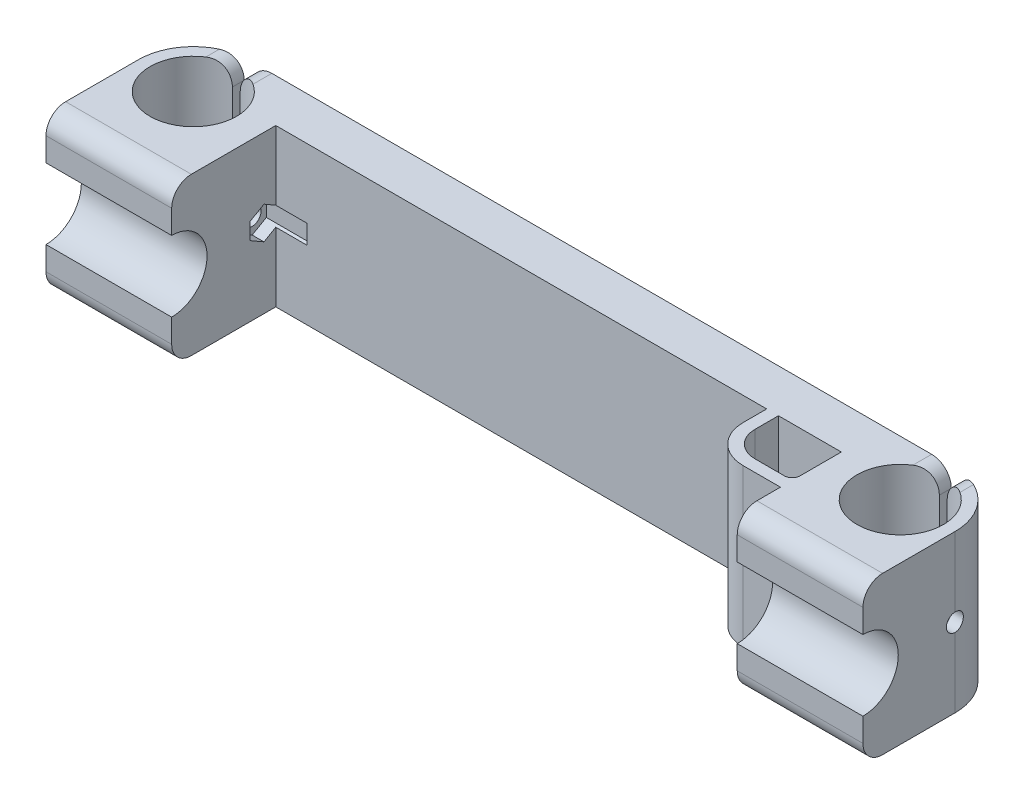
from build123d import *

# Parameters (mm, degrees)
SKETCH1_R               = 11
BOSS_EXTRUDE1_DEPTH     = 40
BOSS_EXTRUDE2_DEPTH     = 32
SKETCH4_W               = 144
SKETCH4_H               = 40
BOSS_EXTRUDE4_DEPTH     = 5
BOSS_EXTRUDE5_DEPTH     = 32
CUT_EXTRUDE2_DEPTH      = 3
SKETCH6_W               = 120
SKETCH6_H               = 20
CUT_EXTRUDE3_DEPTH      = 5
SKETCH8_W               = 2
SKETCH8_H               = 40
CUT_EXTRUDE_THIN1_DEPTH = 18
FILLET2_R               = 5
SKETCH9_R               = 2.25
CUT_EXTRUDE4_DEPTH      = 226
CUT_EXTRUDE5_START      = -3
CUT_EXTRUDE5_DEPTH      = 11
BOSS_EXTRUDE6_DEPTH     = 40
FILLET3_R               = 2


with BuildPart() as part:
    # Sketch1 → Boss-Extrude1 (new body)
    with BuildSketch(Plane(origin=(0, 0, 0), x_dir=(1, 0, 0), z_dir=(0, 1, 0))):
        with BuildLine():
            Line((137.460581558, -14.5), (119.460581558, -14.5))
            Line((119.460581558, -14.5), (119.460581558, 7.5))
            Line((119.460581558, 7.5), (-24.539418442, 7.5))
            Line((-24.539418442, 7.5), (-24.539418442, -14.5))
            Line((-24.539418442, -14.5), (-42.539418442, -14.5))
            Line((-42.539418442, -14.5), (-56.539418442, -14.5))
            Line((-56.539418442, -14.5), (-56.539418442, -0.5))
            ThreePointArc((-56.539418442, -0.5), (-52.438913379, 9.399494937), (-42.539418442, 13.5))
            Line((-42.539418442, 13.5), (137.460581558, 13.5))
            ThreePointArc((137.460581558, 13.5), (147.360076494, 9.399494937), (151.460581558, -0.5))
            Line((151.460581558, -0.5), (151.460581558, -14.5))
            Line((151.460581558, -14.5), (137.460581558, -14.5))
        make_face()
        with Locations((-42.539418442, -0.5)):
            Circle(SKETCH1_R, mode=Mode.SUBTRACT)
        with Locations((137.460581558, -0.5)):
            Circle(SKETCH1_R, mode=Mode.SUBTRACT)
    extrude(amount=BOSS_EXTRUDE1_DEPTH)

    # Sketch2 → Boss-Extrude2 (add)
    with BuildSketch(Plane.ZY.offset(56.539418442)):
        with BuildLine():
            Line((14.5, 40), (19, 40))
            ThreePointArc((19, 40), (22.535533906, 38.535533906), (24, 35))
            Line((24, 35), (24, 29))
            ThreePointArc((24, 29), (15, 20), (24, 11))
            Line((24, 11), (24, 5))
            ThreePointArc((24, 5), (22.535533906, 1.464466094), (19, 0))
            Line((19, 0), (14.5, 0))
            Line((14.5, 0), (14.5, 40))
        make_face()
    extrude(amount=-BOSS_EXTRUDE2_DEPTH)

    # Sketch4 → Boss-Extrude4 (add)
    with BuildSketch(Plane.XY.offset(-7.5)):
        with Locations((47.460581558, 20)):
            Rectangle(SKETCH4_W, SKETCH4_H)
    extrude(amount=BOSS_EXTRUDE4_DEPTH)

    # Sketch3 → Boss-Extrude5 (add)
    with BuildSketch(Plane(origin=(151.460581558, 0, 0), x_dir=(0, 0, -1), z_dir=(1, 0, 0))):
        with BuildLine():
            Line((-24, 11), (-24, 5))
            ThreePointArc((-24, 5), (-22.535533906, 1.464466094), (-19, 0))
            Line((-19, 0), (-14.5, 0))
            Line((-14.5, 0), (-14.5, 40))
            Line((-14.5, 40), (-19, 40))
            ThreePointArc((-19, 40), (-22.535533906, 38.535533906), (-24, 35))
            Line((-24, 35), (-24, 29))
            ThreePointArc((-24, 29), (-15, 20), (-24, 11))
        make_face()
    extrude(amount=-BOSS_EXTRUDE5_DEPTH)

    # Sketch5 → Cut-Extrude2 (cut)
    with BuildSketch(Plane(origin=(0, 0, -13.5), x_dir=(-1, 0, 0), z_dir=(0, 0, -1))):
        with BuildLine():
            Line((32.539418442, 35), (-127.460581558, 35))
            ThreePointArc((-127.460581558, 35), (-130.996115464, 33.535533906), (-132.460581558, 30))
            Line((-132.460581558, 30), (-132.460581558, 10))
            ThreePointArc((-132.460581558, 10), (-130.996115464, 6.464466094), (-127.460581558, 5))
            Line((-127.460581558, 5), (32.539418442, 5))
            ThreePointArc((32.539418442, 5), (36.074952348, 6.464466094), (37.539418442, 10))
            Line((37.539418442, 10), (37.539418442, 30))
            ThreePointArc((37.539418442, 30), (36.074952348, 33.535533906), (32.539418442, 35))
        make_face()
    extrude(amount=-CUT_EXTRUDE2_DEPTH, mode=Mode.SUBTRACT)

    # Sketch6 → Cut-Extrude3 (cut)
    with BuildSketch(Plane(origin=(0, 0, -10.5), x_dir=(-1, 0, 0), z_dir=(0, 0, -1))):
        with Locations((-47.460581558, 20)):
            Rectangle(SKETCH6_W, SKETCH6_H)
    extrude(amount=-CUT_EXTRUDE3_DEPTH, mode=Mode.SUBTRACT)

    # Sketch8 → Cut-Extrude-Thin1 (cut)
    with BuildSketch(Plane(origin=(0, 0, -13.5), x_dir=(-1, 0, 0), z_dir=(0, 0, -1))):
        with Locations((-137.460581558, 20)):
            Rectangle(SKETCH8_W, SKETCH8_H)
        with Locations((42.539418442, 20)):
            Rectangle(SKETCH8_W, SKETCH8_H)
    extrude(amount=-CUT_EXTRUDE_THIN1_DEPTH, mode=Mode.SUBTRACT)

    # Fillet2
    fillet2_edges = [part.edges().sort_by_distance(p)[0] for p in [
        (138.460581558, 0, -11.959345597),
        (138.460581558, 40, -11.959345597),
        (136.460581558, 0, -11.977225575),
        (136.460581558, 40, -11.977225575),
        (-41.539418442, 40, -11.977225575),
        (-43.539418442, 40, -11.959345597),
        (-43.539418442, 0, -11.959345597),
        (-41.539418442, 0, -11.977225575),
    ]]
    fillet(fillet2_edges, radius=FILLET2_R)

    # Sketch9 → Cut-Extrude4 (cut)
    with BuildSketch(Plane(origin=(151.460581558, 0, 0), x_dir=(0, 0, -1), z_dir=(1, 0, 0))):
        with Locations((-0.5, 20)):
            Circle(SKETCH9_R)
    extrude(amount=-CUT_EXTRUDE4_DEPTH, mode=Mode.SUBTRACT)

    # Sketch10 → Cut-Extrude5 (cut)
    with BuildSketch(Plane(origin=(-24.539418442, 0, 0), x_dir=(0, 0, -1), z_dir=(1, 0, 0)).offset(CUT_EXTRUDE5_START)):
        Polygon((-0.5, 24.156921938), (-4.1, 22.078460969), (-4.1, 17.921539031), (-0.5, 15.843078062), (3.1, 17.921539031), (3.1, 22.078460969), align=None)
    cut_extrude5 = extrude(amount=CUT_EXTRUDE5_DEPTH, mode=Mode.SUBTRACT)

    # Mirror5: Cut-Extrude5 across plane
    add(cut_extrude5.mirror(Plane.ZY.offset(-47.460581558)), mode=Mode.SUBTRACT)

    # Sketch12 → Boss-Extrude6 (add)
    with BuildSketch(Plane(origin=(0, 0, 0), x_dir=(-1, 0, 0), z_dir=(0, -1, 0))):
        with BuildLine():
            Line((-103.460581558, -3.5), (-103.460581558, 2.5))
            Line((-103.460581558, 2.5), (-100.460581558, 2.5))
            Line((-100.460581558, 2.5), (-100.460581558, -3.5))
            ThreePointArc((-100.460581558, -3.5), (-103.243067136, -10.217514421), (-109.960581558, -13))
            Line((-109.960581558, -13), (-119.460581558, -13))
            Line((-119.460581558, -13), (-119.460581558, -10))
            Line((-119.460581558, -10), (-116.460581558, -10))
            Line((-116.460581558, -10), (-109.960581558, -10))
            ThreePointArc((-109.960581558, -10), (-105.36438748, -8.096194078), (-103.460581558, -3.5))
        make_face()
    extrude(amount=-BOSS_EXTRUDE6_DEPTH)

    # Fillet3
    fillet3_edges = [part.edges().sort_by_distance(p)[0] for p in [
        (119.460581558, 20, 10),
    ]]
    fillet(fillet3_edges, radius=FILLET3_R)


solid = part.part
